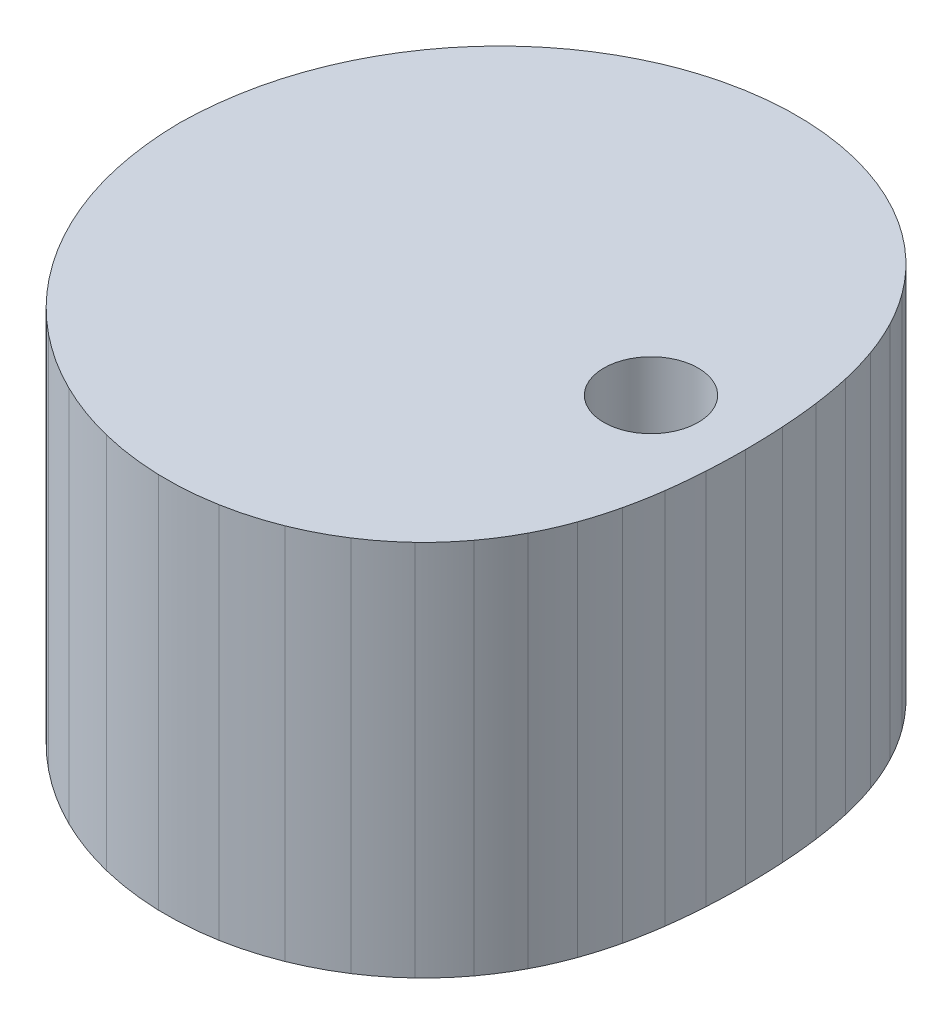
from build123d import *

# Parameters (mm, degrees)
SKETCH1_W               = 123.825
SKETCH1_H               = 25.4
SKETCH2_OUTSIDE_W       = 328.022
SKETCH2_OUTSIDE_H       = 328.022
CUT_EXTRUDE1_DEPTH      = 10
CUT_EXTRUDE1_DEPTH_BACK = 35.4


with BuildPart() as part:
    # Sketch1 → Revolve1 (revolve)
    with BuildSketch(Plane.XY):
        with Locations((65.0875, -12.7)):
            Rectangle(SKETCH1_W, SKETCH1_H)
    revolve(axis=Axis((0, -1254, 0), (0, 1, 0)))

    # Sketch2 outside → Cut-Extrude1 (cut, two sides)
    with BuildSketch(Plane(origin=(0, 0, 0), x_dir=(1, 0, 0), z_dir=(0, 1, 0))) as cut_extrude1_sk:
        Rectangle(SKETCH2_OUTSIDE_W, SKETCH2_OUTSIDE_H)
        with BuildLine():
            ThreePointArc((6.35, 0), (6.329912836, 1.284135818), (6.27254171, 2.56714667))
            ThreePointArc((6.27254171, 2.56714667), (6.175326887, 3.824361251), (6.03246285, 5.077209643))
            ThreePointArc((6.03246285, 5.077209643), (5.842143008, 6.297144559), (5.595092591, 7.506867226))
            ThreePointArc((5.595092591, 7.506867226), (5.286100034, 8.696690934), (4.908320284, 9.866494044))
            ThreePointArc((4.908320284, 9.866494044), (4.445694933, 11.036480903), (3.903262447, 12.17167184))
            ThreePointArc((3.903262447, 12.17167184), (3.246006434, 13.319190062), (2.500680026, 14.411559999))
            ThreePointArc((2.500680026, 14.411559999), (1.608536581, 15.51119354), (0.624958662, 16.529863421))
            ThreePointArc((0.624958662, 16.529863421), (-0.532205476, 17.53111816), (-1.776823287, 18.421323977))
            ThreePointArc((-1.776823287, 18.421323977), (-3.209328759, 19.252740722), (-4.715795066, 19.941133777))
            ThreePointArc((-4.715795066, 19.941133777), (-6.406453621, 20.519055391), (-8.146794068, 20.923449837))
            ThreePointArc((-8.146794068, 20.923449837), (-10.046848772, 21.163603755), (-11.961570845, 21.205090642))
            ThreePointArc((-11.961570845, 21.205090642), (-13.991121641, 21.035122659), (-15.99114089, 20.650559852))
            ThreePointArc((-15.99114089, 20.650559852), (-18.044142393, 20.021705604), (-20.01719815, 19.174755893))
            ThreePointArc((-20.01719815, 19.174755893), (-21.970442626, 18.071028594), (-23.791190022, 16.760205626))
            ThreePointArc((-23.791190022, 16.760205626), (-25.516143096, 15.203834234), (-27.05861892, 13.466444423))
            ThreePointArc((-27.05861892, 13.466444423), (-28.434599881, 11.518792927), (-29.585456445, 9.430205097))
            ThreePointArc((-29.585456445, 9.430205097), (-30.512481977, 7.187988004), (-31.183290683, 4.85626557))
            ThreePointArc((-31.183290683, 4.85626557), (-31.593025755, 2.44288094), (-31.75, 0))
            ThreePointArc((-31.75, 0), (-31.593025755, -2.44288094), (-31.183290683, -4.85626557))
            ThreePointArc((-31.183290683, -4.85626557), (-30.512481977, -7.187988004), (-29.585456445, -9.430205097))
            ThreePointArc((-29.585456445, -9.430205097), (-28.434599881, -11.518792927), (-27.05861892, -13.466444423))
            ThreePointArc((-27.05861892, -13.466444423), (-25.516143096, -15.203834234), (-23.791190022, -16.760205626))
            ThreePointArc((-23.791190022, -16.760205626), (-21.970442626, -18.071028594), (-20.01719815, -19.174755893))
            ThreePointArc((-20.01719815, -19.174755893), (-18.044142393, -20.021705604), (-15.99114089, -20.650559852))
            ThreePointArc((-15.99114089, -20.650559852), (-13.991121641, -21.035122659), (-11.961570845, -21.205090642))
            ThreePointArc((-11.961570845, -21.205090642), (-10.046848772, -21.163603755), (-8.146794068, -20.923449837))
            ThreePointArc((-8.146794068, -20.923449837), (-6.406453621, -20.519055391), (-4.715795066, -19.941133777))
            ThreePointArc((-4.715795066, -19.941133777), (-3.209328759, -19.252740722), (-1.776823287, -18.421323977))
            ThreePointArc((-1.776823287, -18.421323977), (-0.532205476, -17.53111816), (0.624958662, -16.529863421))
            ThreePointArc((0.624958662, -16.529863421), (1.608536581, -15.51119354), (2.500680026, -14.411559999))
            ThreePointArc((2.500680026, -14.411559999), (3.246006434, -13.319190062), (3.903262447, -12.17167184))
            ThreePointArc((3.903262447, -12.17167184), (4.445694933, -11.036480903), (4.908320284, -9.866494044))
            ThreePointArc((4.908320284, -9.866494044), (5.286100034, -8.696690934), (5.595092591, -7.506867226))
            ThreePointArc((5.595092591, -7.506867226), (5.842143008, -6.297144559), (6.03246285, -5.077209643))
            ThreePointArc((6.03246285, -5.077209643), (6.175326887, -3.824361251), (6.27254171, -2.56714667))
            ThreePointArc((6.27254171, -2.56714667), (6.329912836, -1.284135818), (6.35, 0))
        make_face(mode=Mode.SUBTRACT)
    extrude(amount=CUT_EXTRUDE1_DEPTH, mode=Mode.SUBTRACT)
    extrude(cut_extrude1_sk.sketch, amount=-CUT_EXTRUDE1_DEPTH_BACK, mode=Mode.SUBTRACT)


solid = part.part
